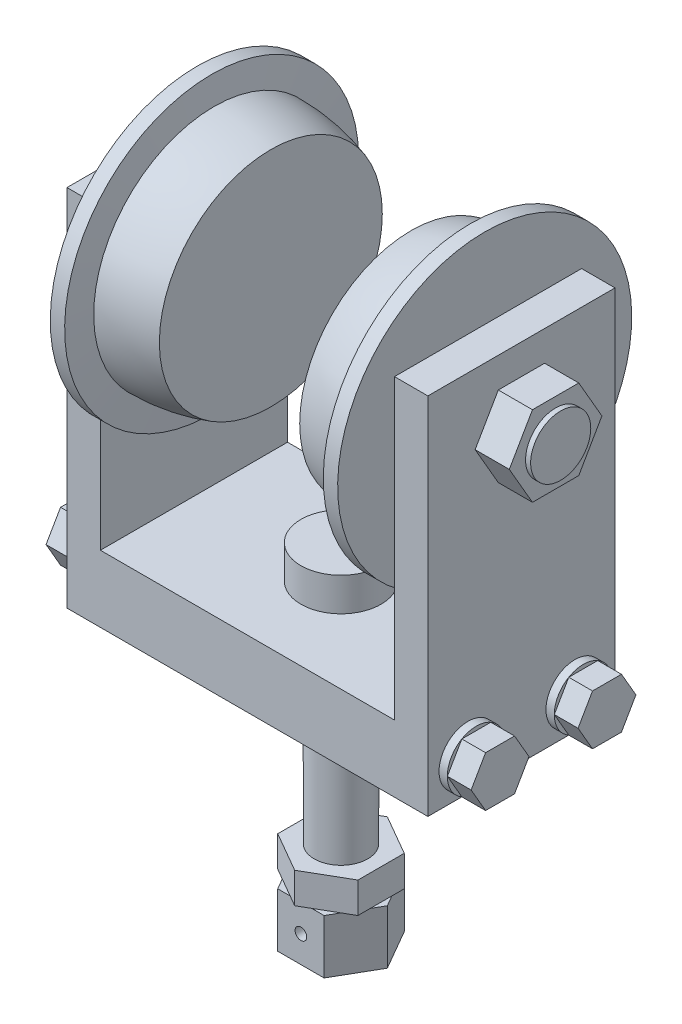
from build123d import *

# Parameters (mm, degrees)
YOKE_CROSS_SECTION_W           = 88.9
YOKE_CROSS_SECTION_H           = 31.75
YOKE_DEPTH                     = 69.85
SIDEPLATE_PROFILE_W            = 88.9
SIDEPLATE_PROFILE_H            = 173.0375
SIDEPLATE_DEPTH                = 15.875
WHEEL_PIN_NUT_DEPTH            = 16.2306
WHEEL_PIN_PROJECTION_PROFILE_R = 14.2875
WHEEL_PIN_PROJECTION_DEPTH     = 2.413
LOCKNUTS_PROFILE_R             = 13.7541
LOCKNUTS_DEPTH                 = 3.9624
SCREWS_DEPTH                   = 11.2776
PROFILE_R                      = 19.05
KING_BOLT_HEAD_DEPTH           = 15.875
DIA_R                          = 12.7
KING_BOLT_DEPTH                = 76.2
KING_BOLT_JAM_NUT_DEPTH        = 14.605
KING_BOLT_NUT_DEPTH            = 25.7048
SKETCH5_R                      = 12.7
EXTENDED_KING_BOLT_DEPTH       = 6.35
CHAMFER1_SIZE                  = 2.38125
COTTER_PIN_HOLE_REACH          = 90.9
SKETCH8_R                      = 2.7686


with BuildPart() as part:
    # YOKE CROSS SECTION → YOKE (new body)
    with BuildSketch(Plane(origin=(0, 0, 0), x_dir=(0, 0, -1), z_dir=(1, 0, 0))):
        with Locations((0, 15.875)):
            Rectangle(YOKE_CROSS_SECTION_W, YOKE_CROSS_SECTION_H)
    extrude(amount=YOKE_DEPTH)

    # SIDEPLATE PROFILE → SIDEPLATE (add)
    with BuildSketch(Plane(origin=(69.85, 0, 0), x_dir=(0, 0, -1), z_dir=(1, 0, 0))):
        with Locations((0, 86.51875)):
            Rectangle(SIDEPLATE_PROFILE_W, SIDEPLATE_PROFILE_H)
    extrude(amount=SIDEPLATE_DEPTH)

    # WHEEL PIN NUT PROFILE → WHEEL PIN NUT (add)
    with BuildSketch(Plane(origin=(85.725, 0, 0), x_dir=(0, 0, -1), z_dir=(1, 0, 0))):
        Polygon((21.997045256, 139.7), (10.998522628, 158.75), (-10.998522628, 158.75), (-21.997045256, 139.7), (-10.998522628, 120.65), (10.998522628, 120.65), align=None)
    extrude(amount=WHEEL_PIN_NUT_DEPTH)

    # WHEEL PIN PROJECTION PROFILE → WHEEL PIN PROJECTION (add)
    with BuildSketch(Plane(origin=(101.9556, 0, 0), x_dir=(0, 0, -1), z_dir=(1, 0, 0))):
        with Locations((0, 139.7)):
            Circle(WHEEL_PIN_PROJECTION_PROFILE_R)
    extrude(amount=WHEEL_PIN_PROJECTION_DEPTH)

    # LOCKNUTS PROFILE → LOCKNUTS (add)
    with BuildSketch(Plane(origin=(85.725, 0, 0), x_dir=(0, 0, -1), z_dir=(1, 0, 0))):
        with Locations((-25.4, 15.875)):
            Circle(LOCKNUTS_PROFILE_R)
    locknuts = extrude(amount=LOCKNUTS_DEPTH)

    # SCREWS PROFILE → SCREWS (add)
    with BuildSketch(Plane(origin=(89.6874, 0, 0), x_dir=(0, 0, -1), z_dir=(1, 0, 0))):
        Polygon((-11.651846715, 15.875), (-18.525923357, 27.78125), (-32.274076643, 27.78125), (-39.148153285, 15.875), (-32.274076643, 3.96875), (-18.525923357, 3.96875), align=None)
    screws = extrude(amount=SCREWS_DEPTH)

    # PROFILE → KING BOLT HEAD (add)
    with BuildSketch(Plane(origin=(0, 31.75, 0), x_dir=(-1, 0, 0), z_dir=(0, 1, 0))):
        with Locations(Location((0, 0, 0), (0, 0, 90))):  # turned: the seam where the file's is
            Circle(PROFILE_R)
    extrude(amount=KING_BOLT_HEAD_DEPTH)

    # Mirror1: LOCKNUTS, SCREWS across plane
    add(locknuts.mirror(Plane.XY))
    add(screws.mirror(Plane.XY))

    # Mirror5: part across plane


with BuildPart() as part_1:
    add(part.part)
    add(part.part.mirror(Plane(origin=(0, 0, 0), x_dir=(0, 0, 1), z_dir=(1, 0, 0))))

    # DIA. → KING BOLT (add)
    with BuildSketch(Plane.XZ):
        with Locations(Location((0, 0, 0), (0, 0, 90))):  # turned: the seam where the file's is
            Circle(DIA_R)
    extrude(amount=KING_BOLT_DEPTH)

    # KING BOLT JAN NUT PROFILE → KING BOLT JAM NUT (add)
    with BuildSketch(Plane.XZ.offset(76.2)):
        Polygon((0, -21.997045256), (19.05, -10.998522628), (19.05, 10.998522628), (0, 21.997045256), (-19.05, 10.998522628), (-19.05, -10.998522628), align=None)
    extrude(amount=KING_BOLT_JAM_NUT_DEPTH)

    # KING BOLT NUT PROFILE → KING BOLT NUT (add)
    with BuildSketch(Plane.XZ.offset(90.805)):
        Polygon((21.997045256, 0), (10.998522628, 19.05), (-10.998522628, 19.05), (-21.997045256, 0), (-10.998522628, -19.05), (10.998522628, -19.05), align=None)
    extrude(amount=KING_BOLT_NUT_DEPTH)

    # Sketch5 → EXTENDED KING BOLT (add)
    with BuildSketch(Plane.XZ.offset(116.5098)):
        with Locations(Location((0, 0, 0), (0, 0, 90))):  # turned: the seam where the file's is
            Circle(SKETCH5_R)
    extrude(amount=EXTENDED_KING_BOLT_DEPTH)

    # Chamfer1
    chamfer1_edges = [part_1.edges().sort_by_distance(p)[0] for p in [
        (0, -122.8598, -12.7),
    ]]
    chamfer(chamfer1_edges, length=CHAMFER1_SIZE)

    # Sketch7 → WHEEL (revolve)
    with BuildSketch(Plane.XY):
        with BuildLine():
            Line((68.2625, 155.575), (68.2625, 209.55))
            Line((68.2625, 209.55), (61.436106027, 209.55))
            Line((61.436106027, 209.55), (60.325, 196.85))
            ThreePointArc((60.325, 196.85), (46.669179212, 195.794911968), (33.3375, 192.654691982))
            Line((33.3375, 192.654691982), (33.3375, 139.7))
            Line((33.3375, 139.7), (69.85, 139.7))
            Line((69.85, 139.7), (69.85, 155.575))
            Line((69.85, 155.575), (68.2625, 155.575))
        make_face()
    wheel = revolve(axis=Axis((69.85, 139.7, 0), (-1, 0, 0)))

    # Mirror6: WHEEL across plane
    add(wheel.mirror(Plane(origin=(0, 0, 0), x_dir=(0, 0, 1), z_dir=(1, 0, 0))))

    # Sketch8 → COTTER PIN HOLE (cut, up to next)
    with BuildSketch(Plane.XY.offset(19.05), mode=Mode.PRIVATE) as cotter_pin_hole_sk1:
        with Locations((0, -103.8098)):
            Circle(SKETCH8_R)
    cotter_pin_hole_tool1 = extrude(cotter_pin_hole_sk1.sketch, amount=-COTTER_PIN_HOLE_REACH, mode=Mode.PRIVATE) & part_1.part
    add(cotter_pin_hole_tool1.solids().sort_by_distance((0, -103.8098, 19.05))[0], mode=Mode.SUBTRACT)


solid = part_1.part
